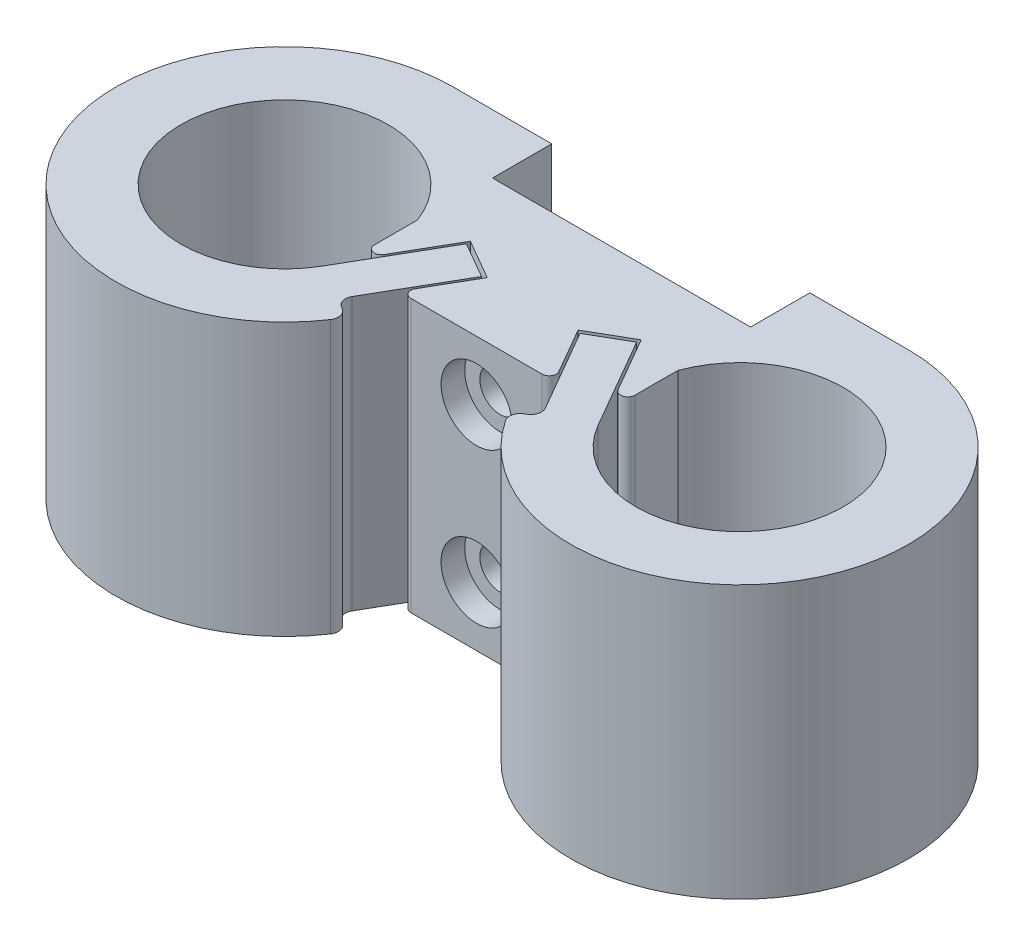
from build123d import *

# Parameters (mm, degrees)
SKETCH1_W               = 22
SKETCH1_H               = 6
BOSS_EXTRUDE1_DEPTH     = 23
BOSS_EXTRUDE2_DEPTH     = 23
BOSS_EXTRUDE3_DEPTH     = 23
CUT_EXTRUDE1_DEPTH      = 24
SKETCH5_W               = 20
SKETCH5_H               = 2
BOSS_EXTRUDE4_DEPTH     = 45
SKETCH6_W               = 1
SKETCH6_H               = 2
BOSS_EXTRUDE5_DEPTH     = 20
BOSS_EXTRUDE6_DEPTH     = 23
FILLET1_R               = 0.6
BOSS_EXTRUDE7_DEPTH     = 23
FILLET2_R               = 0.9
SKETCH10_W              = 21.8
SKETCH10_H              = 5
CUT_EXTRUDE2_DEPTH      = 23
CUT_EXTRUDE2_DEPTH_BACK = 24
SKETCH11_R              = 1.725
CUT_EXTRUDE3_DEPTH      = 18.25
SKETCH12_R              = 3
CUT_EXTRUDE4_DEPTH      = 2


with BuildPart() as part:
    # Sketch1 → Boss-Extrude1 (new body)
    with BuildSketch(Plane(origin=(0, 0, 0), x_dir=(1, 0, 0), z_dir=(0, 1, 0))):
        Rectangle(SKETCH1_W, SKETCH1_H)
    extrude(amount=BOSS_EXTRUDE1_DEPTH)

    # Sketch2 → Boss-Extrude2 (add)
    with BuildSketch(Plane(origin=(0, 23, 0), x_dir=(1, 0, 0), z_dir=(0, 1, 0))):
        with BuildLine():
            Line((-11, 3), (-7.342667591, 3))
            ThreePointArc((-7.342667591, 3), (-31.353026246, 1.686257741), (-8.610829915, -6.125))
            Line((-8.610829915, -6.125), (-11.641918828, -4.375))
            ThreePointArc((-11.641918828, -4.375), (-27.936683546, 0.758729989), (-11, 3))
        make_face()
        with BuildLine():
            Line((11.641918828, -4.375), (8.610829915, -6.125))
            ThreePointArc((8.610829915, -6.125), (31.353026246, 1.686257741), (7.342667591, 3))
            Line((7.342667591, 3), (11, 3))
            ThreePointArc((11, 3), (27.936683546, 0.758729989), (11.641918828, -4.375))
        make_face()
    extrude(amount=-BOSS_EXTRUDE2_DEPTH)

    # Sketch3 → Boss-Extrude3 (add)
    with BuildSketch(Plane(origin=(0, 23, 0), x_dir=(1, 0, 0), z_dir=(0, 1, 0))):
        with BuildLine():
            Line((-19.219641111, 12.25), (19.219641111, 12.25))
            ThreePointArc((19.219641111, 12.25), (11.692606503, 9.66469089), (7.342667591, 3))
            Line((7.342667591, 3), (-7.342667591, 3))
            ThreePointArc((-7.342667591, 3), (-11.692606503, 9.66469089), (-19.219641111, 12.25))
        make_face()
    extrude(amount=-BOSS_EXTRUDE3_DEPTH)

    # Sketch8 → Cut-Extrude1 (cut, through all)
    with BuildSketch(Plane.XZ):
        Polygon((11, 2.863163975), (7.215123909, -3.692433715), (3.837624834, -1.742433715), (6.575670216, 3), (11, 3), align=None)
        Polygon((-6.575670216, 3), (-11, 3), (-11, 2.863163975), (-7.215123909, -3.692433715), (-3.837624834, -1.742433715), align=None)
    extrude(amount=-CUT_EXTRUDE1_DEPTH, mode=Mode.SUBTRACT)

    # Sketch5 → Boss-Extrude4 (add)
    with BuildSketch(Plane(origin=(0, 23, 0), x_dir=(1, 0, 0), z_dir=(0, 1, 0))):
        with Locations((0, 13.25)):
            Rectangle(SKETCH5_W, SKETCH5_H)
    extrude(amount=-BOSS_EXTRUDE4_DEPTH)

    # Sketch6 → Boss-Extrude5 (add)
    with BuildSketch(Plane.ZY.offset(10)):
        with Locations((-11.75, -21)):
            Rectangle(SKETCH6_W, SKETCH6_H)
        Polygon((-11.25, -20), (-11.25, -22), (-9.25, -22), (-9.25, -1), (-11.25, -1), align=None)
    extrude(amount=-BOSS_EXTRUDE5_DEPTH)

    # Sketch9 → Boss-Extrude6 (add)
    with BuildSketch(Plane.XZ):
        Polygon((4.160829915, -1.582626094), (8.610829915, 6.125), (11.641918828, 4.375), (7.191918828, -3.332626094), align=None)
        Polygon((-7.191918828, -3.332626094), (-4.160829915, -1.582626094), (-8.610829915, 6.125), (-11.641918828, 4.375), align=None)
    extrude(amount=-BOSS_EXTRUDE6_DEPTH)

    # Fillet1
    fillet1_edges = [part.edges().sort_by_distance(p)[0] for p in [
        (11, 11.5, 2.863163975),
        (6.575670216, 11.5, 3),
        (-6.575670216, 11.5, 3),
        (-11, 11.5, 2.863163975),
    ]]
    fillet(fillet1_edges, radius=FILLET1_R)

    # Sketch7 → Boss-Extrude7 (add)
    with BuildSketch(Plane(origin=(0, 23, 0), x_dir=(1, 0, 0), z_dir=(0, 1, 0))):
        with BuildLine():
            Line((10, 14.25), (19.219641111, 14.25))
            ThreePointArc((19.219641111, 14.25), (31.560503115, -7.125), (6.878779107, -7.125))
            Line((6.878779107, -7.125), (8.610829915, -6.125))
            ThreePointArc((8.610829915, -6.125), (29.828452308, -6.125), (19.219641111, 12.25))
            Line((19.219641111, 12.25), (10, 12.25))
            Line((10, 12.25), (10, 14.25))
        make_face()
        with BuildLine():
            Line((-8.610829915, -6.125), (-6.878779107, -7.125))
            ThreePointArc((-6.878779107, -7.125), (-31.560503115, -7.125), (-19.219641111, 14.25))
            Line((-19.219641111, 14.25), (-10, 14.25))
            Line((-10, 14.25), (-10, 12.25))
            Line((-10, 12.25), (-19.219641111, 12.25))
            ThreePointArc((-19.219641111, 12.25), (-29.828452308, -6.125), (-8.610829915, -6.125))
        make_face()
    extrude(amount=-BOSS_EXTRUDE7_DEPTH)

    # Fillet2
    fillet2_edges = [part.edges().sort_by_distance(p)[0] for p in [
        (0, -22, -9.25),
        (-8.610829915, 11.5, 6.125),
        (6.878779107, 11.5, 7.125),
        (10, 0, -13.25),
        (-6.878779107, 11.5, 7.125),
        (-10, 0, -13.25),
        (8.610829915, 11.5, 6.125),
        (0, -22, -14.25),
    ]]
    fillet(fillet2_edges, radius=FILLET2_R)

    # Sketch10 → Cut-Extrude2 (cut, two sides)
    with BuildSketch(Plane.XZ) as cut_extrude2_sk:
        with Locations((0, -11.75)):
            Rectangle(SKETCH10_W, SKETCH10_H)
    extrude(amount=CUT_EXTRUDE2_DEPTH, mode=Mode.SUBTRACT)
    extrude(cut_extrude2_sk.sketch, amount=-CUT_EXTRUDE2_DEPTH_BACK, mode=Mode.SUBTRACT)

    # Sketch11 → Cut-Extrude3 (cut, through all)
    with BuildSketch(Plane.XY.offset(3)):
        with Locations((0, 5)):
            Circle(SKETCH11_R)
        with Locations((0, 18)):
            Circle(SKETCH11_R)
    extrude(amount=-CUT_EXTRUDE3_DEPTH, mode=Mode.SUBTRACT)

    # Sketch12 → Cut-Extrude4 (cut)
    with BuildSketch(Plane.XY.offset(3)):
        with Locations((0, 5)):
            Circle(SKETCH12_R)
        with Locations((0, 18)):
            Circle(SKETCH12_R)
    extrude(amount=-CUT_EXTRUDE4_DEPTH, mode=Mode.SUBTRACT)


solid = part.part
